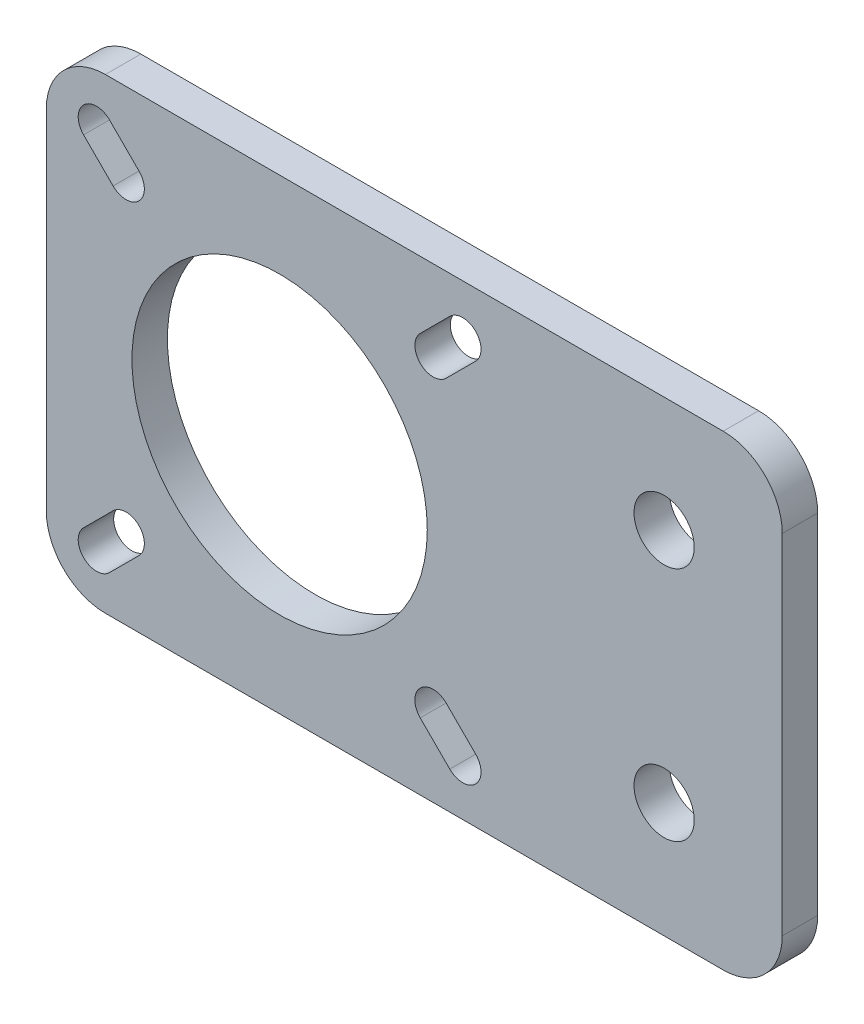
from build123d import *

# Parameters (mm, degrees)
SKETCH1_W           = 62.3
SKETCH1_H           = 39.5
SKETCH1_R           = 12.5
SKETCH1_R_2         = 2.55
BOSS_EXTRUDE1_DEPTH = 3
FILLET1_R           = 5


with BuildPart() as part:
    # Sketch1 → Boss-Extrude1 (new body)
    with BuildSketch(Plane.XY):
        with Locations((31.15, 19.75)):
            Rectangle(SKETCH1_W, SKETCH1_H)
        with Locations((19.75, 19.75)):
            Circle(SKETCH1_R, mode=Mode.SUBTRACT)
        with Locations((52.3, 29.75)):
            Circle(SKETCH1_R_2, mode=Mode.SUBTRACT)
        with Locations((52.3, 9.75)):
            Circle(SKETCH1_R_2, mode=Mode.SUBTRACT)
        with BuildLine():
            Line((5.346015511, 36.346015511), (7.846015511, 33.846015511))
            ThreePointArc((7.846015511, 33.846015511), (7.846015511, 31.653984489), (5.653984489, 31.653984489))
            Line((5.653984489, 31.653984489), (3.153984489, 34.153984489))
            ThreePointArc((3.153984489, 34.153984489), (3.153984489, 36.346015511), (5.346015511, 36.346015511))
        make_face(mode=Mode.SUBTRACT)
        with BuildLine():
            Line((34.153984489, 36.346015511), (31.653984489, 33.846015511))
            ThreePointArc((31.653984489, 33.846015511), (31.653984489, 31.653984489), (33.846015511, 31.653984489))
            Line((33.846015511, 31.653984489), (36.346015511, 34.153984489))
            ThreePointArc((36.346015511, 34.153984489), (36.346015511, 36.346015511), (34.153984489, 36.346015511))
        make_face(mode=Mode.SUBTRACT)
        with BuildLine():
            Line((34.153984489, 3.153984489), (31.653984489, 5.653984489))
            ThreePointArc((31.653984489, 5.653984489), (31.653984489, 7.846015511), (33.846015511, 7.846015511))
            Line((33.846015511, 7.846015511), (36.346015511, 5.346015511))
            ThreePointArc((36.346015511, 5.346015511), (36.346015511, 3.153984489), (34.153984489, 3.153984489))
        make_face(mode=Mode.SUBTRACT)
        with BuildLine():
            Line((5.346015511, 3.153984489), (7.846015511, 5.653984489))
            ThreePointArc((7.846015511, 5.653984489), (7.846015511, 7.846015511), (5.653984489, 7.846015511))
            Line((5.653984489, 7.846015511), (3.153984489, 5.346015511))
            ThreePointArc((3.153984489, 5.346015511), (3.153984489, 3.153984489), (5.346015511, 3.153984489))
        make_face(mode=Mode.SUBTRACT)
    extrude(amount=BOSS_EXTRUDE1_DEPTH)

    # Fillet1
    fillet1_edges = [part.edges().sort_by_distance(p)[0] for p in [
        (0, 39.5, 1.5),
        (62.3, 39.5, 1.5),
        (62.3, 0, 1.5),
        (0, 0, 1.5),
    ]]
    fillet(fillet1_edges, radius=FILLET1_R)


solid = part.part
